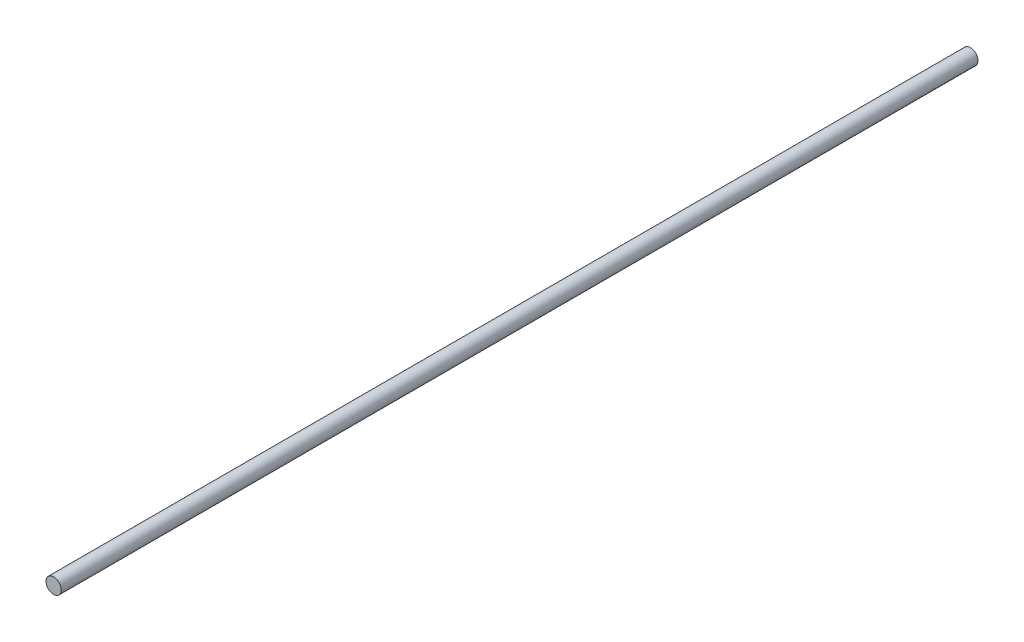
from build123d import *

# Parameters (mm, degrees)
ESQUISSE1_R        = 4
BOSS_EXTRU_1_DEPTH = 480


with BuildPart() as part:
    # Esquisse1 → Boss.-Extru.1 (new body)
    with BuildSketch(Plane.XY):
        Circle(ESQUISSE1_R)
    extrude(amount=BOSS_EXTRU_1_DEPTH)


solid = part.part
